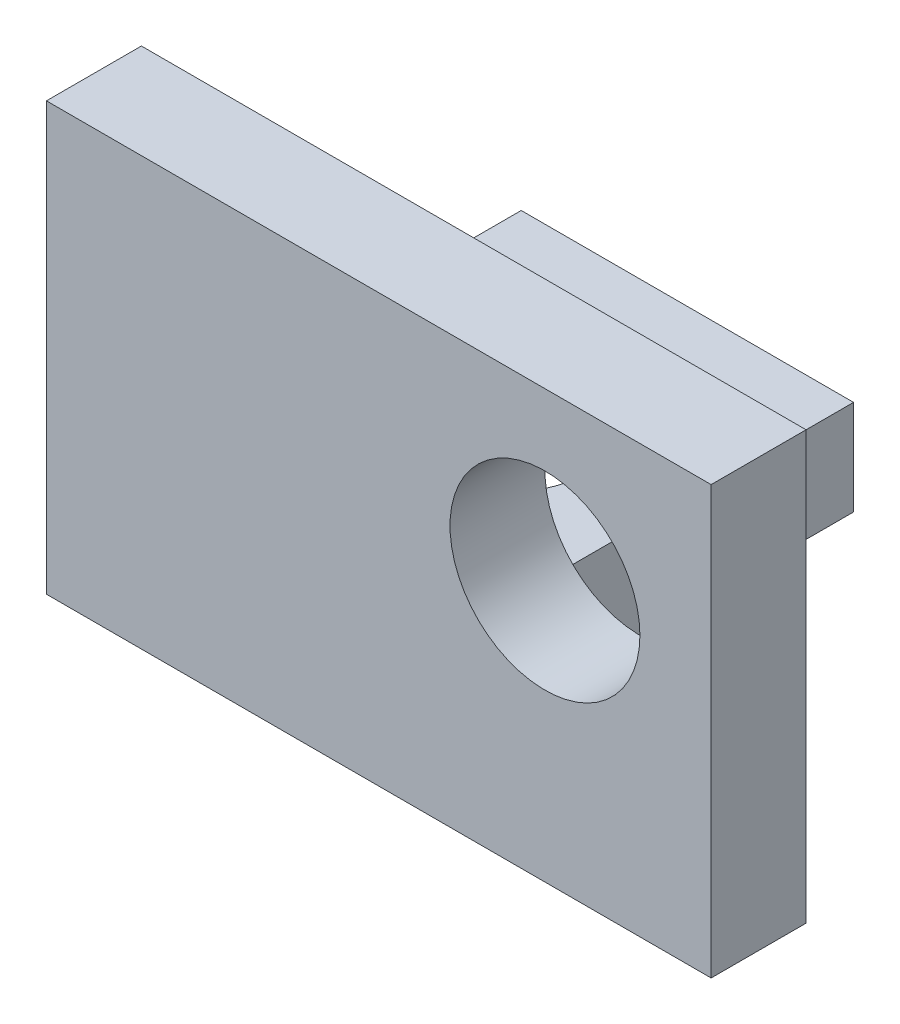
from build123d import *

# Parameters (mm, degrees)
SKETCH1_W           = 8.89
SKETCH1_H           = 12.7
SKETCH1_R           = 2.54
BOSS_EXTRUDE1_DEPTH = 2.54
SKETCH2_W           = 17.78
SKETCH2_H           = 11.43
SKETCH2_R           = 2.54
BOSS_EXTRUDE2_DEPTH = 2.54


with BuildPart() as part:
    # Sketch1 → Boss-Extrude1 (new body)
    with BuildSketch(Plane(origin=(0, 0, 0), x_dir=(1, 0, 0), z_dir=(0, 1, 0))):
        with Locations((-4.445, -6.35)):
            Rectangle(SKETCH1_W, SKETCH1_H)
        with Locations((-4.445, -5.08)):
            Circle(SKETCH1_R, mode=Mode.SUBTRACT)
    extrude(amount=BOSS_EXTRUDE1_DEPTH)

    # Sketch2 → Boss-Extrude2 (add)
    with BuildSketch(Plane.XY.offset(12.7)):
        with Locations((0, 5.715)):
            Rectangle(SKETCH2_W, SKETCH2_H)
        with Locations((4.445, 6.985)):
            Circle(SKETCH2_R, mode=Mode.SUBTRACT)
    extrude(amount=-BOSS_EXTRUDE2_DEPTH)


solid = part.part
